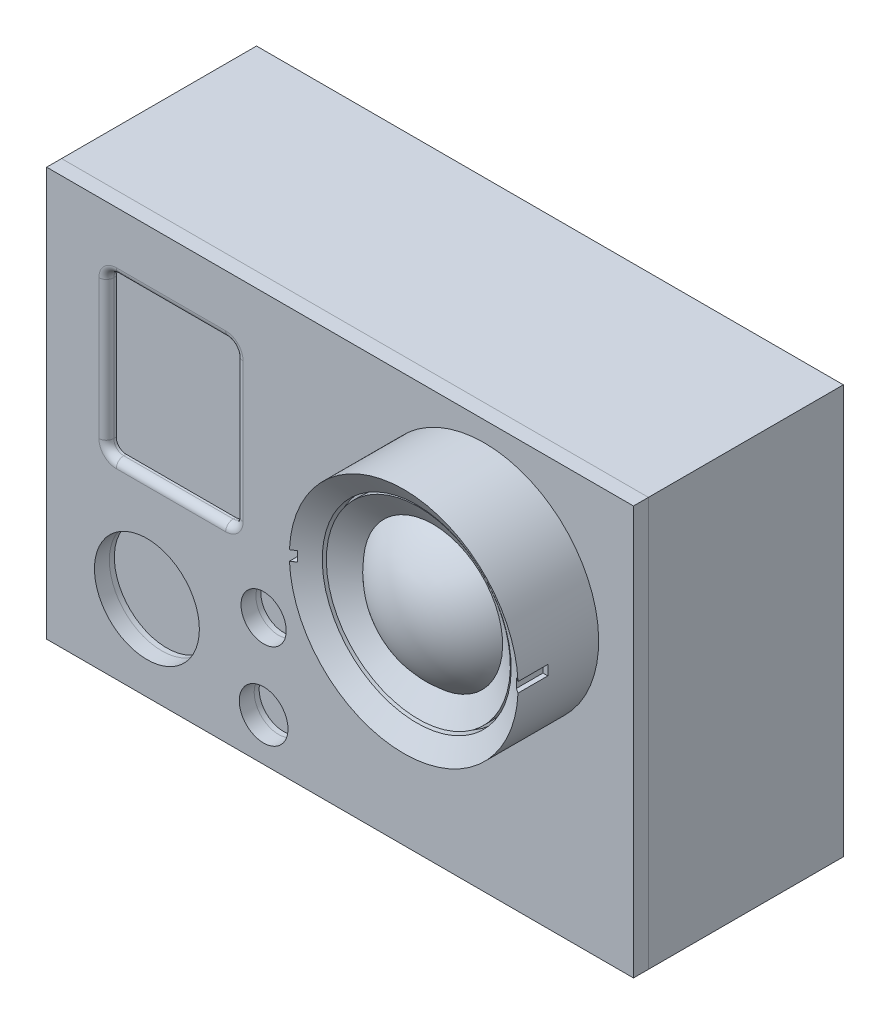
from build123d import *

# Parameters (mm, degrees)
SKETCH1_W              = 59
SKETCH1_H              = 41.1
BOSS_EXTRUDE1_DEPTH    = 19.6
SKETCH2_W              = 59
SKETCH2_H              = 41.1
BOSS_EXTRUDE2_DEPTH    = 1.5
LENS_START             = 8.1
SKETCH5_W              = 0.5
SKETCH5_H              = 1
LENS_SIDE_CUTS_DEPTH   = 3
SCREEN_CUT_DEPTH       = 1
FILLET1_R              = 0.75
SKETCH7_R              = 5.274271813
SKETCH7_R_2            = 2.274069125
SKETCH7_R_3            = 2.44866529
BUTTON_CUTS_FACE_DEPTH = 2


with BuildPart() as part:
    # Sketch1 → Boss-Extrude1 (new body)
    with BuildSketch(Plane.XY):
        Rectangle(SKETCH1_W, SKETCH1_H)
    extrude(amount=BOSS_EXTRUDE1_DEPTH)


with BuildPart() as body_2:
    # Sketch2 → Boss-Extrude2 (new body)
    with BuildSketch(Plane.XY.offset(19.6)):
        Rectangle(SKETCH2_W, SKETCH2_H)
    extrude(amount=BOSS_EXTRUDE2_DEPTH)

    # Sketch4 → lens (revolve)
    with BuildSketch(Plane(origin=(14.5, 0, 0), x_dir=(0, 0, -1), z_dir=(1, 0, 0))):
        with BuildLine():
            Line((-21.1, 7.05), (-29.6, 7.05))
            ThreePointArc((-29.6, 7.05), (-28.721320344, 10.928679656), (-26.256854249, 14.05))
            Line((-26.256854249, 14.05), (-27.728427125, 16.3))
            Line((-27.728427125, 16.3), (-26.891935222, 16.3))
            Line((-26.891935222, 16.3), (-26.891935222, 16.55))
            Line((-26.891935222, 16.55), (-27.891935222, 16.55))
            Line((-27.891935222, 16.55), (-29.2, 18.55))
            Line((-29.2, 18.55), (-21.1, 18.55))
            Line((-21.1, 18.55), (-21.1, 7.05))
        make_face()
    revolve(axis=Axis((14.5, 7.05, 21.1), (0, 0, 1)))

    # Sketch5 → lens side cuts (cut)
    with BuildSketch(Plane.XY.offset(21.1).offset(LENS_START)):
        with Locations((25.75, 7.05)):
            Rectangle(SKETCH5_W, SKETCH5_H)
        with Locations((3.25, 7.05)):
            Rectangle(SKETCH5_W, SKETCH5_H)
    extrude(amount=-LENS_SIDE_CUTS_DEPTH, mode=Mode.SUBTRACT)

    # Sketch6 → Screen cut (cut)
    with BuildSketch(Plane.XY.offset(21.1)):
        with BuildLine():
            Line((-22.5, 14.55), (-11.5, 14.55))
            ThreePointArc((-11.5, 14.55), (-10.792893219, 14.257106781), (-10.5, 13.55))
            Line((-10.5, 13.55), (-10.5, -0.45))
            ThreePointArc((-10.5, -0.45), (-10.792893219, -1.157106781), (-11.5, -1.45))
            Line((-11.5, -1.45), (-22.5, -1.45))
            ThreePointArc((-22.5, -1.45), (-23.207106781, -1.157106781), (-23.5, -0.45))
            Line((-23.5, -0.45), (-23.5, 13.55))
            ThreePointArc((-23.5, 13.55), (-23.207106781, 14.257106781), (-22.5, 14.55))
        make_face()
    extrude(amount=-SCREEN_CUT_DEPTH, mode=Mode.SUBTRACT)

    # Fillet1
    fillet1_edges = [body_2.edges().sort_by_distance(p)[0] for p in [
        (-23.207106781, -1.157106781, 21.1),
        (-17, -1.45, 21.1),
        (-10.792893219, -1.157106781, 21.1),
        (-10.5, 6.55, 21.1),
        (-10.792893219, 14.257106781, 21.1),
        (-17, 14.55, 21.1),
        (-23.207106781, 14.257106781, 21.1),
        (-23.5, 6.55, 21.1),
    ]]
    fillet(fillet1_edges, radius=FILLET1_R)


with BuildPart() as button_cuts_face_tool:
    # Sketch7 → Button cuts - Face (new body)
    with BuildSketch(Plane.XY.offset(21.1)):
        with Locations((-19.420550326, -12.006300701)):
            Circle(SKETCH7_R)
        with Locations((-7.686353642, -7.777316407)):
            Circle(SKETCH7_R_2)
        with Locations((-7.686353642, -16.235284994)):
            Circle(SKETCH7_R_3)
    extrude(amount=-BUTTON_CUTS_FACE_DEPTH)


with BuildPart() as part_1:
    add(part.part)

    # Button cuts - Face: cut by button_cuts_face_tool
    add(button_cuts_face_tool.part, mode=Mode.SUBTRACT)


with BuildPart() as body_2_1:
    add(body_2.part)

    # Button cuts - Face: cut by button_cuts_face_tool
    add(button_cuts_face_tool.part, mode=Mode.SUBTRACT)


solid = Compound([part_1.part, body_2_1.part])
